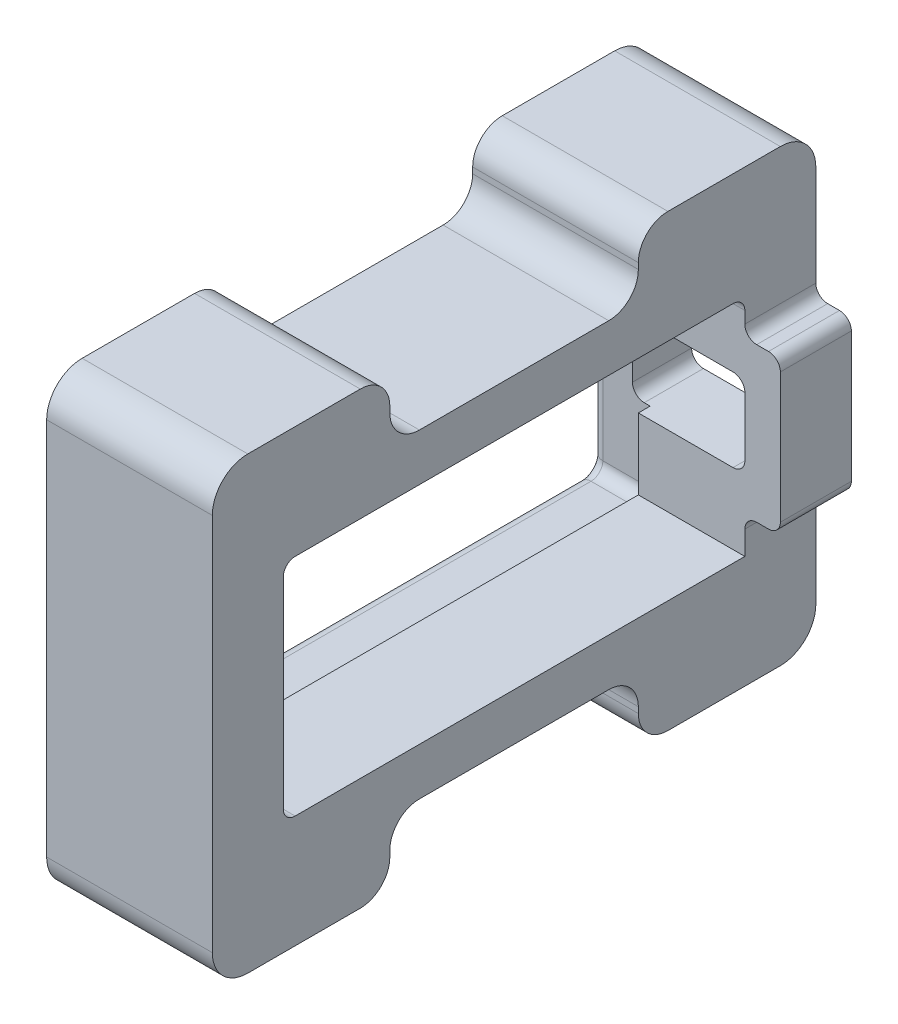
from build123d import *

# Parameters (mm, degrees)
SKETCH1_W                   = 51
SKETCH1_H                   = 38
SKETCH1_W_2                 = 41
SKETCH1_H_2                 = 21
MAIN_BODY_DEPTH             = 10
SKETCH2_W                   = 41
SKETCH2_H                   = 21
SKETCH2_W_2                 = 39
SKETCH2_H_2                 = 19
END_STOP_DEPTH              = 5
CONTOURING_R                = 1
SKETCH4_W                   = 21
SKETCH4_H                   = 5.5
CLEARANCE_MIDDLE_DEPTH      = 21
EDGE_CONTOURING_R           = 3
INNER_CONTOURING_R          = 2.5
FIT_CONTOURING_R            = 1
SKETCH5_W                   = 15.358498738
SKETCH5_H                   = 54.278463244
SINGLE_CUT_DEPTH            = 52
SKETCH6_W                   = 13
SKETCH6_H                   = 7
CLEARANCE_WIRE_DEPTH        = 6
SKETCH7_W                   = 3
SKETCH7_H                   = 13
WIRE_CAP_DEPTH              = 6
WIRE_CLEARANCE_CONTOURING_R = 1


with BuildPart() as part:
    # Sketch1 → Main Body (new body, symmetric)
    with BuildSketch(Plane(origin=(0, 0, 0), x_dir=(0, 0, -1), z_dir=(1, 0, 0))):
        Rectangle(SKETCH1_W, SKETCH1_H)
        Rectangle(SKETCH1_W_2, SKETCH1_H_2, mode=Mode.SUBTRACT)
    extrude(amount=MAIN_BODY_DEPTH, both=True)

    # Sketch2 → End Stop (add, symmetric)
    with BuildSketch(Plane(origin=(0, 0, 0), x_dir=(0, 0, -1), z_dir=(1, 0, 0))):
        Rectangle(SKETCH2_W, SKETCH2_H)
        Rectangle(SKETCH2_W_2, SKETCH2_H_2, mode=Mode.SUBTRACT)
    extrude(amount=END_STOP_DEPTH, both=True)

    # Contouring
    contouring_edges = [part.edges().sort_by_distance(p)[0] for p in [
        (7.5, 10.5, 20.5),
        (7.5, -10.5, 20.5),
        (7.5, -10.5, -20.5),
        (7.5, 10.5, -20.5),
        (-7.5, 10.5, -20.5),
        (-7.5, 10.5, 20.5),
        (-7.5, -10.5, -20.5),
        (-7.5, -10.5, 20.5),
        (0, 9.5, 19.5),
        (0, -9.5, 19.5),
        (0, 9.5, -19.5),
    ]]
    fillet(contouring_edges, radius=CONTOURING_R)

    # Sketch4 → Clearance - Middle (cut, through all)
    with BuildSketch(Plane(origin=(10, 0, 0), x_dir=(0, 0, -1), z_dir=(1, 0, 0))):
        with Locations((0, 16.25)):
            Rectangle(SKETCH4_W, SKETCH4_H)
        with Locations((0, -16.25)):
            Rectangle(SKETCH4_W, SKETCH4_H)
    extrude(amount=-CLEARANCE_MIDDLE_DEPTH, mode=Mode.SUBTRACT)

    # Edge Contouring
    edge_contouring_edges = [part.edges().sort_by_distance(p)[0] for p in [
        (0, 19, 25.5),
        (0, 19, -25.5),
        (0, -19, -25.5),
        (0, -19, 25.5),
    ]]
    fillet(edge_contouring_edges, radius=EDGE_CONTOURING_R)

    # Inner Contouring
    inner_contouring_edges = [part.edges().sort_by_distance(p)[0] for p in [
        (0, 13.5, 10.5),
        (0, 19, 10.5),
        (0, 19, -10.5),
        (0, 13.5, -10.5),
        (0, -19, -10.5),
        (0, -19, 10.5),
        (0, -13.5, 10.5),
        (0, -13.5, -10.5),
    ]]
    fillet(inner_contouring_edges, radius=INNER_CONTOURING_R)

    # Fit Contouring
    fit_contouring_edges = [part.edges().sort_by_distance(p)[0] for p in [
        (-10, -10.5, 0),
        (-10, 0, -20.5),
        (-10, 0, 20.5),
        (10, 0, -20.5),
        (10, 10.5, 0),
        (-10, 10.5, 0),
        (10, 0, 20.5),
        (10, -10.5, 0),
        (-10, -10.207106781, -20.207106781),
        (-10, -10.207106781, 20.207106781),
        (10, 10.207106781, -20.207106781),
        (-10, 10.207106781, -20.207106781),
        (-10, 10.207106781, 20.207106781),
        (10, 10.207106781, 20.207106781),
        (10, -10.207106781, 20.207106781),
        (10, -10.207106781, -20.207106781),
    ]]
    fillet(fit_contouring_edges, radius=FIT_CONTOURING_R)

    # Sketch5 → Single Cut (cut, through all)
    with BuildSketch(Plane(origin=(0, 0, -25.5), x_dir=(-1, 0, 0), z_dir=(0, 0, -1))):
        with Locations((-11.679249369, 0)):
            Rectangle(SKETCH5_W, SKETCH5_H)
    extrude(amount=-SINGLE_CUT_DEPTH, mode=Mode.SUBTRACT)

    # Sketch6 → Clearance - Wire (cut)
    with BuildSketch(Plane(origin=(0, 0, -25.5), x_dir=(-1, 0, 0), z_dir=(0, 0, -1))):
        Rectangle(SKETCH6_W, SKETCH6_H)
    extrude(amount=-CLEARANCE_WIRE_DEPTH, mode=Mode.SUBTRACT)

    # Sketch7 → Wire Cap (add)
    with BuildSketch(Plane(origin=(0, 0, -25.5), x_dir=(-1, 0, 0), z_dir=(0, 0, -1))):
        with Locations((-5.5, 0)):
            Rectangle(SKETCH7_W, SKETCH7_H)
    extrude(amount=-WIRE_CAP_DEPTH)

    # Wire Clearance Contouring
    wire_clearance_contouring_edges = [part.edges().sort_by_distance(p)[0] for p in [
        (4, -3.5, -22.5),
        (4, 3.5, -22.5),
        (-6.5, -3.5, -23),
        (-6.5, 3.5, -23),
        (4, 6.5, -22.5),
        (7, 6.5, -22.5),
        (7, -6.5, -22.5),
        (4, -6.5, -22.5),
    ]]
    fillet(wire_clearance_contouring_edges, radius=WIRE_CLEARANCE_CONTOURING_R)


solid = part.part
